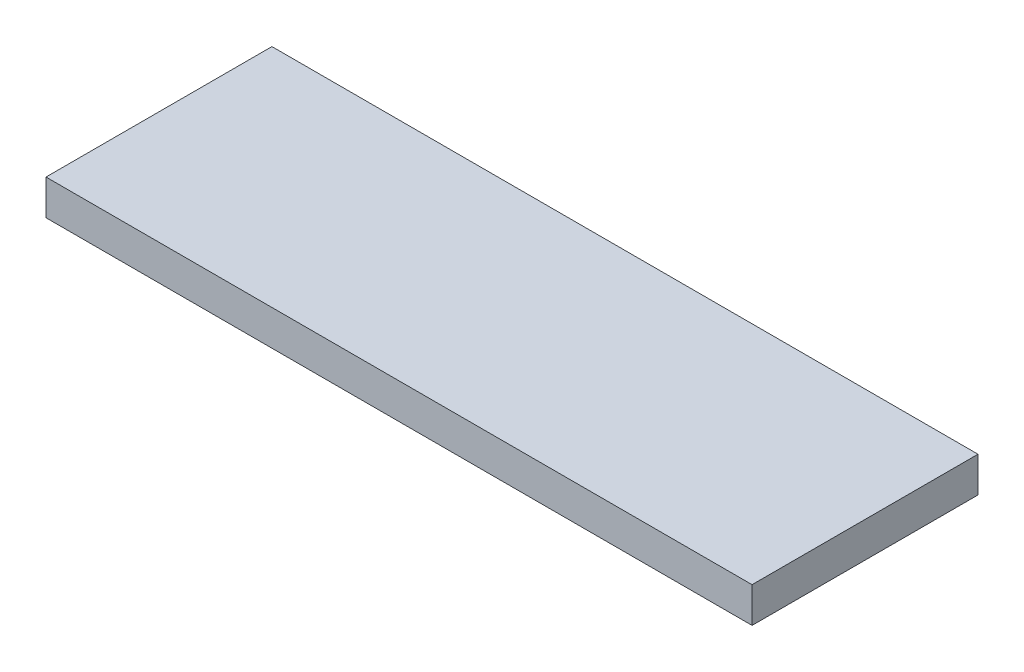
from build123d import *

# Parameters (mm, degrees)
CROQUIS1_W              = 100
CROQUIS1_H              = 32
SALIENTE_EXTRUIR1_DEPTH = 5


with BuildPart() as part:
    # Croquis1 → Saliente-Extruir1 (new body)
    with BuildSketch(Plane(origin=(0, 0, 0), x_dir=(1, 0, 0), z_dir=(0, 1, 0))):
        Rectangle(CROQUIS1_W, CROQUIS1_H)
    extrude(amount=SALIENTE_EXTRUIR1_DEPTH)


solid = part.part
